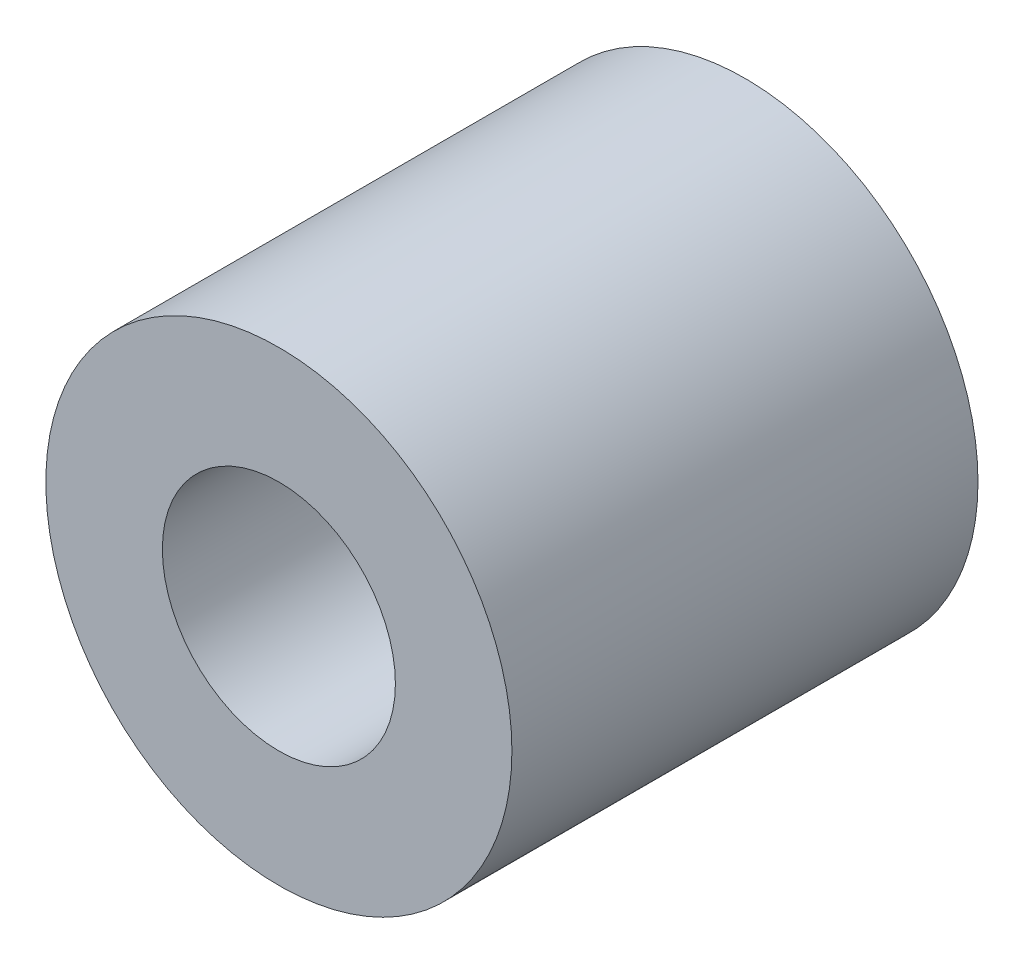
from build123d import *

# Parameters (mm, degrees)
SKETCH_1_R      = 8
SKETCH_1_R_2    = 4
EXTRUDE_1_DEPTH = 16


with BuildPart() as part:
    # 草图1 → 凸台-拉伸1 (new body)
    with BuildSketch(Plane.XY):
        Circle(SKETCH_1_R)
        Circle(SKETCH_1_R_2, mode=Mode.SUBTRACT)
    extrude(amount=EXTRUDE_1_DEPTH)


solid = part.part
